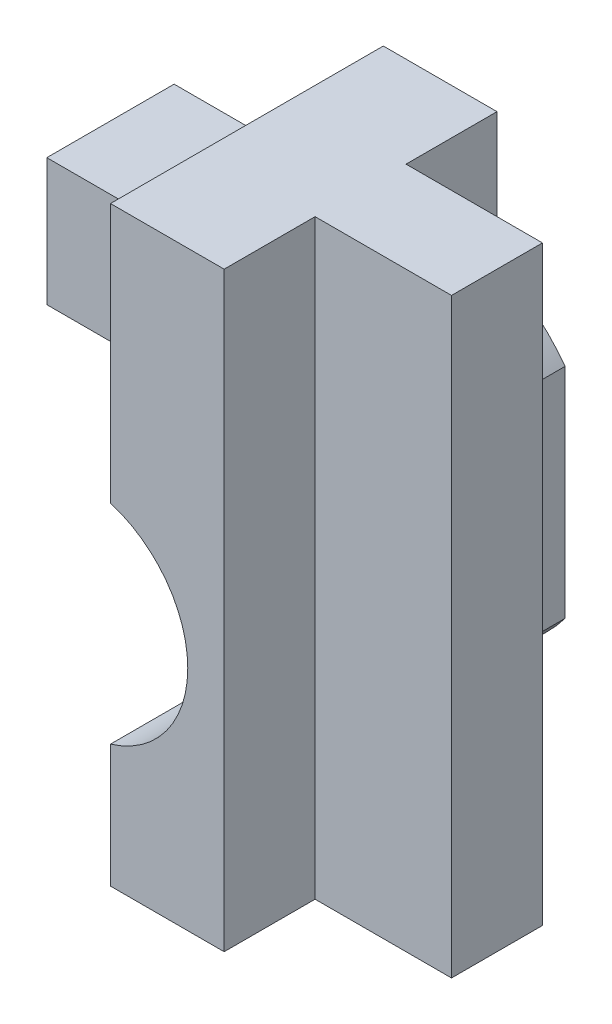
from build123d import *

# Parameters (mm, degrees)
SKETCH1_R            = 1
BOSS_EXTRUDE1_DEPTH  = 6
SKETCH2_R            = 2.6
CUT_EXTRUDE1_DEPTH   = 6
SKETCH3_W            = 7.6
SKETCH3_H            = 13
BOSS_EXTRUDE2_DEPTH  = 6
BOSS_EXTRUDE5_START  = -5
SKETCH6_W            = 3
SKETCH6_H            = 2
BOSS_EXTRUDE5_DEPTH  = 13
BOSS_EXTRUDE6_START  = -7.5
SKETCH10_R           = 4
SKETCH10_R_2         = 2.6
BOSS_EXTRUDE6_DEPTH  = 1.5
BOSS_EXTRUDE7_START  = -6
SKETCH12_R           = 2.6
SKETCH12_R_2         = 2.4
BOSS_EXTRUDE7_DEPTH  = 2
CUT_EXTRUDE2_DEPTH   = 7
SKETCH14_W           = 3
SKETCH14_H           = 6
CUT_EXTRUDE3_DEPTH   = 2
SKETCH15_W           = 0.2
SKETCH15_H           = 13
CUT_EXTRUDE5_DEPTH   = 7.5
SKETCH16_W           = 3
SKETCH16_H           = 3
CUT_EXTRUDE6_DEPTH   = 3
SKETCH17_W           = 2.8
SKETCH17_H           = 2.8
BOSS_EXTRUDE9_DEPTH  = 3
BOSS_EXTRUDE10_START = 24.4
SKETCH17_2_W         = 2.8
SKETCH17_2_H         = 2.8
BOSS_EXTRUDE10_DEPTH = 3
SKETCH18_W           = 37.3
SKETCH18_H           = 13
CUT_EXTRUDE11_DEPTH  = 9
SKETCH20_W           = 2.8
SKETCH20_H           = 2.8
BOSS_EXTRUDE11_DEPTH = 3


with BuildPart() as part:
    # Sketch1 → Boss-Extrude1 (new body)
    with BuildSketch(Plane.XY):
        with BuildLine():
            ThreePointArc((3.75, -5), (4.47902769, -4.358991965), (5.1, -3.61282438))
            Line((5.1, -3.61282438), (5.1, 3.61282438))
            ThreePointArc((5.1, 3.61282438), (0, 6.25), (-5.1, 3.61282438))
            Line((-5.1, 3.61282438), (-5.1, -3.61282438))
            ThreePointArc((-5.1, -3.61282438), (-4.47902769, -4.358991965), (-3.75, -5))
            Line((-3.75, -5), (-14.7, -5))
            Line((-14.7, -5), (-14.7, 8))
            Line((-14.7, 8), (14.7, 8))
            Line((14.7, 8), (14.7, -5))
            Line((14.7, -5), (3.75, -5))
        make_face()
        with Locations((11.5, 0)):
            Circle(SKETCH1_R, mode=Mode.SUBTRACT)
        with Locations((-11.5, 0)):
            Circle(SKETCH1_R, mode=Mode.SUBTRACT)
    extrude(amount=BOSS_EXTRUDE1_DEPTH)

    # Sketch2 → Cut-Extrude1 (cut)
    with BuildSketch(Plane.XY):
        with Locations((-11.5, 0)):
            Circle(SKETCH2_R)
        with Locations((11.5, 0)):
            Circle(SKETCH2_R)
    extrude(amount=CUT_EXTRUDE1_DEPTH, mode=Mode.SUBTRACT)

    # Sketch3 → Boss-Extrude2 (add)
    with BuildSketch(Plane.XY):
        with Locations((-18.5, 1.5)):
            Rectangle(SKETCH3_W, SKETCH3_H)
    extrude(amount=BOSS_EXTRUDE2_DEPTH)

    # Sketch6 → Boss-Extrude5 (add)
    with BuildSketch(Plane(origin=(0, 0, 0), x_dir=(1, 0, 0), z_dir=(0, 1, 0)).offset(BOSS_EXTRUDE5_START)):
        with Locations((-23.8, -3)):
            Rectangle(SKETCH6_W, SKETCH6_H)
        with Locations((16.2, -3)):
            Rectangle(SKETCH6_W, SKETCH6_H)
    extrude(amount=BOSS_EXTRUDE5_DEPTH)

    # Sketch10 → Boss-Extrude6 (add)
    with BuildSketch(Plane.XY.offset(6).offset(BOSS_EXTRUDE6_START)):
        with Locations((-11.5, 0)):
            Circle(SKETCH10_R)
        with Locations((-11.5, 0)):
            Circle(SKETCH10_R_2, mode=Mode.SUBTRACT)
        with BuildLine():
            Line((14.7, 2.4), (14.7, -2.4))
            ThreePointArc((14.7, -2.4), (7.5, 0), (14.7, 2.4))
        make_face()
        with Locations((11.5, 0)):
            Circle(SKETCH10_R_2, mode=Mode.SUBTRACT)
    extrude(amount=BOSS_EXTRUDE6_DEPTH)

    # Sketch12 → Boss-Extrude7 (add)
    with BuildSketch(Plane(origin=(0, 0, 0), x_dir=(-1, 0, 0), z_dir=(0, 0, -1)).offset(BOSS_EXTRUDE7_START)):
        with Locations((11.5, 0)):
            Circle(SKETCH12_R)
        with Locations((11.5, 0)):
            Circle(SKETCH12_R_2, mode=Mode.SUBTRACT)
        with Locations((-11.5, 0)):
            Circle(SKETCH12_R)
        with Locations((-11.5, 0)):
            Circle(SKETCH12_R_2, mode=Mode.SUBTRACT)
    extrude(amount=BOSS_EXTRUDE7_DEPTH)

    # Sketch13 → Cut-Extrude2 (cut)
    with BuildSketch(Plane.XZ.offset(5)):
        Polygon((-22.3, 0), (-16.3, 0), (-16.3, 2), (-17.8, 2), (-17.8, 6), (-20.8, 6), (-20.8, 2), (-22.3, 2), align=None)
    extrude(amount=-CUT_EXTRUDE2_DEPTH, mode=Mode.SUBTRACT)

    # Sketch14 → Cut-Extrude3 (cut)
    with BuildSketch(Plane(origin=(0, 0, 0), x_dir=(-1, 0, 0), z_dir=(0, 0, -1))):
        with Locations((19.3, 5)):
            Rectangle(SKETCH14_W, SKETCH14_H)
    extrude(amount=-CUT_EXTRUDE3_DEPTH, mode=Mode.SUBTRACT)

    # Sketch15 → Cut-Extrude5 (cut, symmetric)
    with BuildSketch(Plane.XY):
        with Locations((-12.1, 1.5)):
            Rectangle(SKETCH15_W, SKETCH15_H)
        with Locations((12.1, 1.5)):
            Rectangle(SKETCH15_W, SKETCH15_H)
    extrude(amount=CUT_EXTRUDE5_DEPTH, both=True, mode=Mode.SUBTRACT)

    # Sketch16 → Cut-Extrude6 (cut)
    with BuildSketch(Plane(origin=(12, 0, 0), x_dir=(0, 0, -1), z_dir=(1, 0, 0))):
        with Locations((-3, 5.173669459)):
            Rectangle(SKETCH16_W, SKETCH16_H)
    cut_extrude6 = extrude(amount=-CUT_EXTRUDE6_DEPTH, mode=Mode.SUBTRACT)

    # Mirror1: Cut-Extrude6 across plane
    add(cut_extrude6.mirror(Plane(origin=(0, 0, 0), x_dir=(0, 0, 1), z_dir=(1, 0, 0))), mode=Mode.SUBTRACT)

    # Sketch17 → Boss-Extrude9 (add)
    with BuildSketch(Plane(origin=(-12.2, 0, 0), x_dir=(0, 0, -1), z_dir=(1, 0, 0))):
        with Locations((-3, 5.173669459)):
            Rectangle(SKETCH17_W, SKETCH17_H)
    extrude(amount=BOSS_EXTRUDE9_DEPTH)

    # Sketch17_2 → Boss-Extrude10 (add)
    with BuildSketch(Plane(origin=(-12.2, 0, 0), x_dir=(0, 0, -1), z_dir=(1, 0, 0)).offset(BOSS_EXTRUDE10_START)):
        with Locations((-3, 5.173669459)):
            Rectangle(SKETCH17_2_W, SKETCH17_2_H)
    extrude(amount=-BOSS_EXTRUDE10_DEPTH)

    # Sketch18 → Cut-Extrude11 (cut, symmetric)
    with BuildSketch(Plane.XY):
        with Locations((-6.65, 1.5)):
            Rectangle(SKETCH18_W, SKETCH18_H)
    extrude(amount=CUT_EXTRUDE11_DEPTH, both=True, mode=Mode.SUBTRACT)

    # Sketch20 → Boss-Extrude11 (add)
    with BuildSketch(Plane.ZY.offset(-12.2)):
        with Locations((3, 5.173669459)):
            Rectangle(SKETCH20_W, SKETCH20_H)
    extrude(amount=BOSS_EXTRUDE11_DEPTH)


solid = part.part
